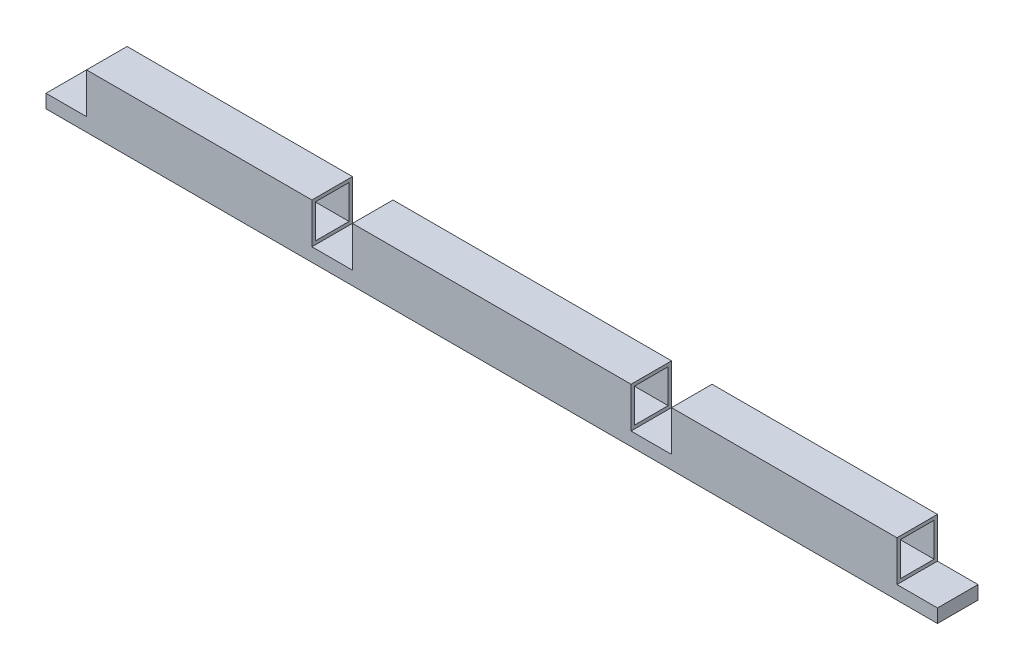
from build123d import *

# Parameters (mm, degrees)
SKETCH1_W           = 838.1
SKETCH1_H           = 12.7
BOSS_EXTRUDE1_DEPTH = 38.1
SKETCH2_W           = 211.9
SKETCH2_H           = 38.1
SKETCH2_W_2         = 261.9
BOSS_EXTRUDE2_DEPTH = 38.1
SKETCH6_W           = 31.75
SKETCH6_H           = 31.75
CUT_EXTRUDE2_DEPTH  = 801


with BuildPart() as part:
    # Sketch1 → Boss-Extrude1 (new body)
    with BuildSketch(Plane.XY):
        with Locations((419.05, 6.35)):
            Rectangle(SKETCH1_W, SKETCH1_H)
    extrude(amount=-BOSS_EXTRUDE1_DEPTH)

    # Sketch2 → Boss-Extrude2 (add)
    with BuildSketch(Plane(origin=(0, 12.7, 0), x_dir=(1, 0, 0), z_dir=(0, 1, 0))):
        with Locations((144.05, 19.05)):
            Rectangle(SKETCH2_W, SKETCH2_H)
        with Locations((419.05, 19.05)):
            Rectangle(SKETCH2_W_2, SKETCH2_H)
        with Locations((694.05, 19.05)):
            Rectangle(SKETCH2_W, SKETCH2_H)
    extrude(amount=BOSS_EXTRUDE2_DEPTH)

    # Sketch6 → Cut-Extrude2 (cut, through all)
    with BuildSketch(Plane.ZY.offset(-38.1)):
        with Locations((-19.05, 31.75)):
            Rectangle(SKETCH6_W, SKETCH6_H)
    extrude(amount=-CUT_EXTRUDE2_DEPTH, mode=Mode.SUBTRACT)


solid = part.part
